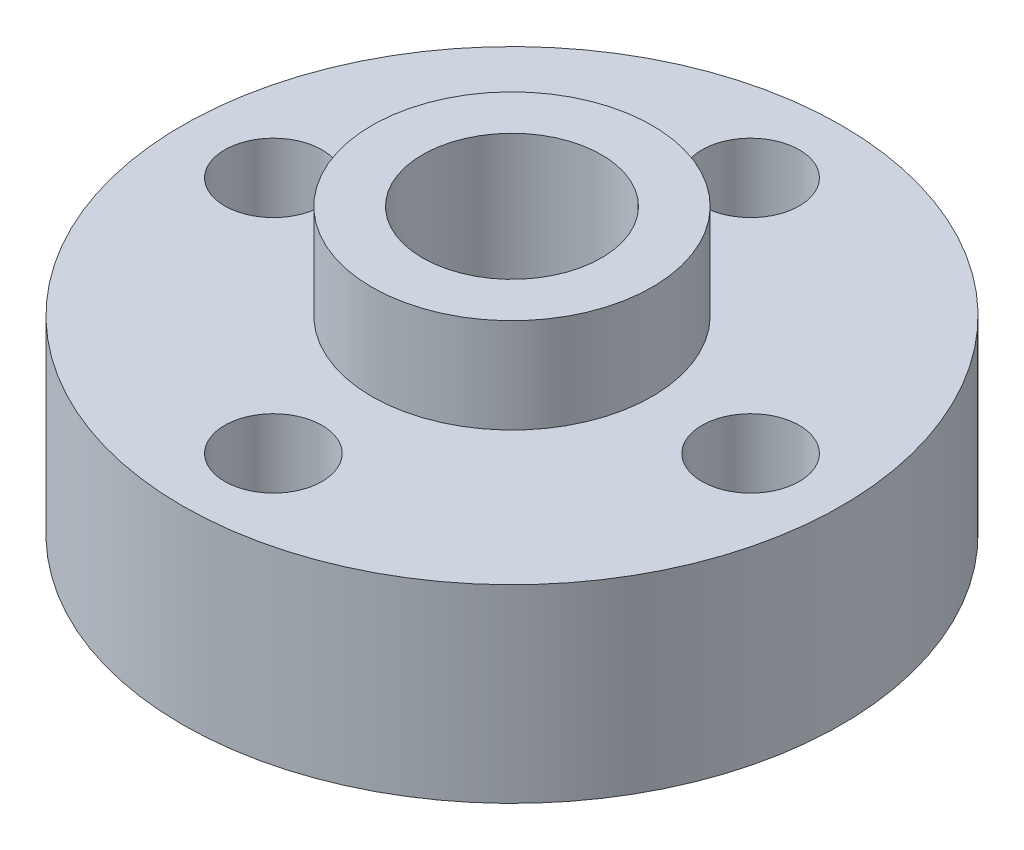
from build123d import *

# Parameters (mm, degrees)
SKETCH1_R           = 4.699
SKETCH1_R_2         = 3
BOSS_EXTRUDE1_DEPTH = 6.35
SKETCH1_3_R         = 11.049
SKETCH1_3_R_2       = 1.63195
SKETCH1_3_R_3       = 4.699
BOSS_EXTRUDE2_DEPTH = 3.175


with BuildPart() as part:
    # Sketch1 → Boss-Extrude1 (new, symmetric)
    with BuildSketch(Plane(origin=(0, 0, 0), x_dir=(1, 0, 0), z_dir=(0, 1, 0))):
        Circle(SKETCH1_R)
        Circle(SKETCH1_R_2, mode=Mode.SUBTRACT)
    extrude(amount=BOSS_EXTRUDE1_DEPTH, both=True)

    # Sketch1_3 → Boss-Extrude2 (add, symmetric)
    with BuildSketch(Plane(origin=(0, 0, 0), x_dir=(1, 0, 0), z_dir=(0, 1, 0))):
        Circle(SKETCH1_3_R)
        with Locations((-8, 0)):
            Circle(SKETCH1_3_R_2, mode=Mode.SUBTRACT)
        Circle(SKETCH1_3_R_3, mode=Mode.SUBTRACT)
        with Locations((0, -8)):
            Circle(SKETCH1_3_R_2, mode=Mode.SUBTRACT)
        with Locations((0, 8)):
            Circle(SKETCH1_3_R_2, mode=Mode.SUBTRACT)
        with Locations((8, 0)):
            Circle(SKETCH1_3_R_2, mode=Mode.SUBTRACT)
    extrude(amount=BOSS_EXTRUDE2_DEPTH, both=True)


solid = part.part
